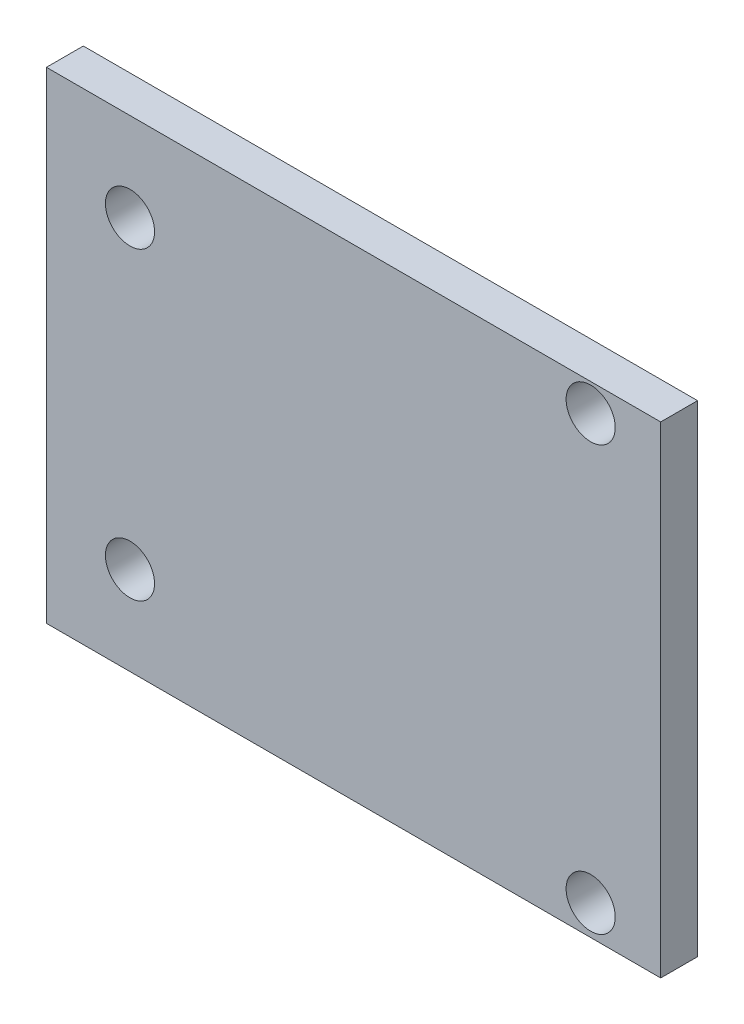
from build123d import *

# Parameters (mm, degrees)
SKETCH1_W           = 50
SKETCH1_H           = 39.2
SKETCH1_R           = 2
BOSS_EXTRUDE1_DEPTH = 3


with BuildPart() as part:
    # Sketch1 → Boss-Extrude1 (new body)
    with BuildSketch(Plane.XY):
        Rectangle(SKETCH1_W, SKETCH1_H)
        with Locations((-18.2, -12.4)):
            Circle(SKETCH1_R, mode=Mode.SUBTRACT)
        with Locations((-18.2, 12.4)):
            Circle(SKETCH1_R, mode=Mode.SUBTRACT)
        with Locations((19.3, -17.15)):
            Circle(SKETCH1_R, mode=Mode.SUBTRACT)
        with Locations((19.3, 17.35)):
            Circle(SKETCH1_R, mode=Mode.SUBTRACT)
    extrude(amount=BOSS_EXTRUDE1_DEPTH)


solid = part.part
